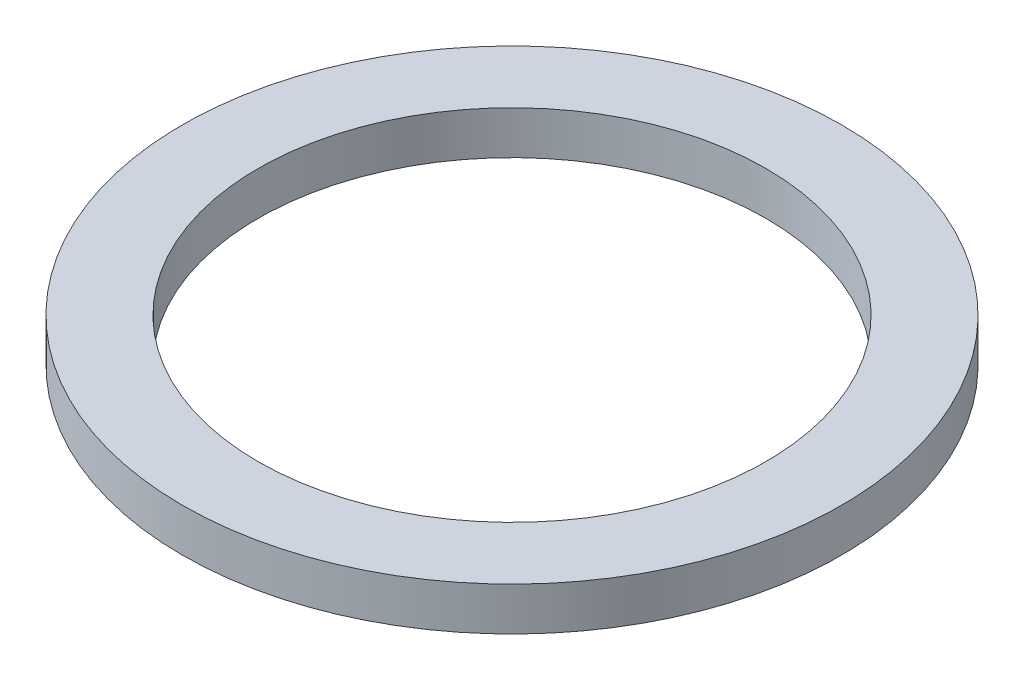
from build123d import *

# Parameters (mm, degrees)
SKETCH1_R           = 30.5
SKETCH1_R_2         = 23.5
BOSS_EXTRUDE1_DEPTH = 4


with BuildPart() as part:
    # Sketch1 → Boss-Extrude1 (new body)
    with BuildSketch(Plane(origin=(0, 0, 0), x_dir=(1, 0, 0), z_dir=(0, 1, 0))):
        Circle(SKETCH1_R)
        Circle(SKETCH1_R_2, mode=Mode.SUBTRACT)
    extrude(amount=BOSS_EXTRUDE1_DEPTH)


solid = part.part
